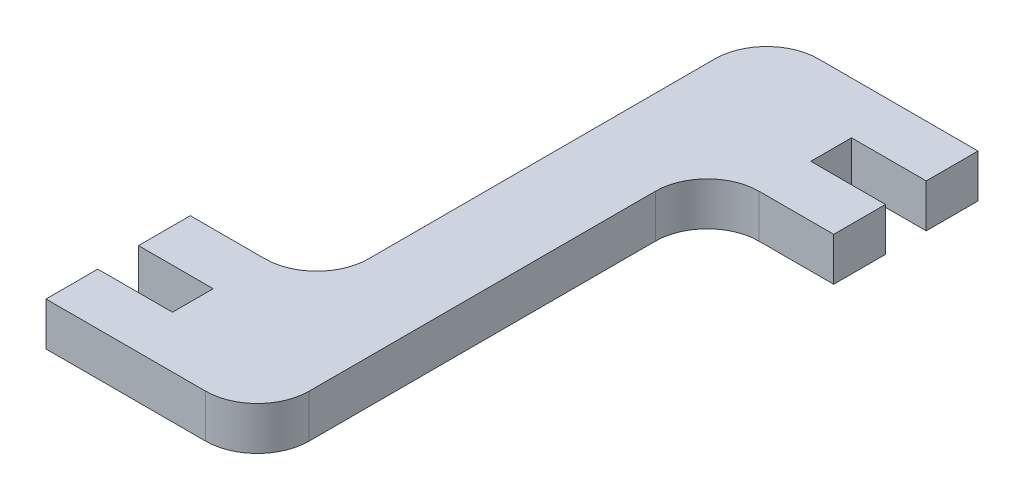
from build123d import *

# Parameters (mm, degrees)
SALIENTE_EXTRUIR1_DEPTH = 5.1


with BuildPart() as part:
    # Croquis1 → Saliente-Extruir1 (new body)
    with BuildSketch(Plane(origin=(0, 0, 0), x_dir=(1, 0, 0), z_dir=(0, 1, 0))):
        with BuildLine():
            Line((0, 0), (18.8, 0))
            ThreePointArc((18.8, 0), (23.113351365, 1.786648635), (24.9, 6.1))
            Line((24.9, 6.1), (24.9, 46.9))
            ThreePointArc((24.9, 46.9), (26.686648635, 51.213351365), (31, 53))
            Line((31, 53), (39.8, 53))
            Line((39.8, 53), (39.8, 59.1))
            Line((39.8, 59.1), (31, 59.1))
            Line((31, 59.1), (31, 63.9))
            Line((31, 63.9), (39.8, 63.9))
            Line((39.8, 63.9), (39.8, 70))
            Line((39.8, 70), (21, 70))
            ThreePointArc((21, 70), (16.686648635, 68.213351365), (14.9, 63.9))
            Line((14.9, 63.9), (14.9, 23.1))
            ThreePointArc((14.9, 23.1), (13.113351365, 18.786648635), (8.8, 17))
            Line((8.8, 17), (0, 17))
            Line((0, 17), (0, 10.9))
            Line((0, 10.9), (8.8, 10.9))
            Line((8.8, 10.9), (8.8, 6.1))
            Line((8.8, 6.1), (0, 6.1))
            Line((0, 6.1), (0, 0))
        make_face()
    extrude(amount=SALIENTE_EXTRUIR1_DEPTH)


solid = part.part
